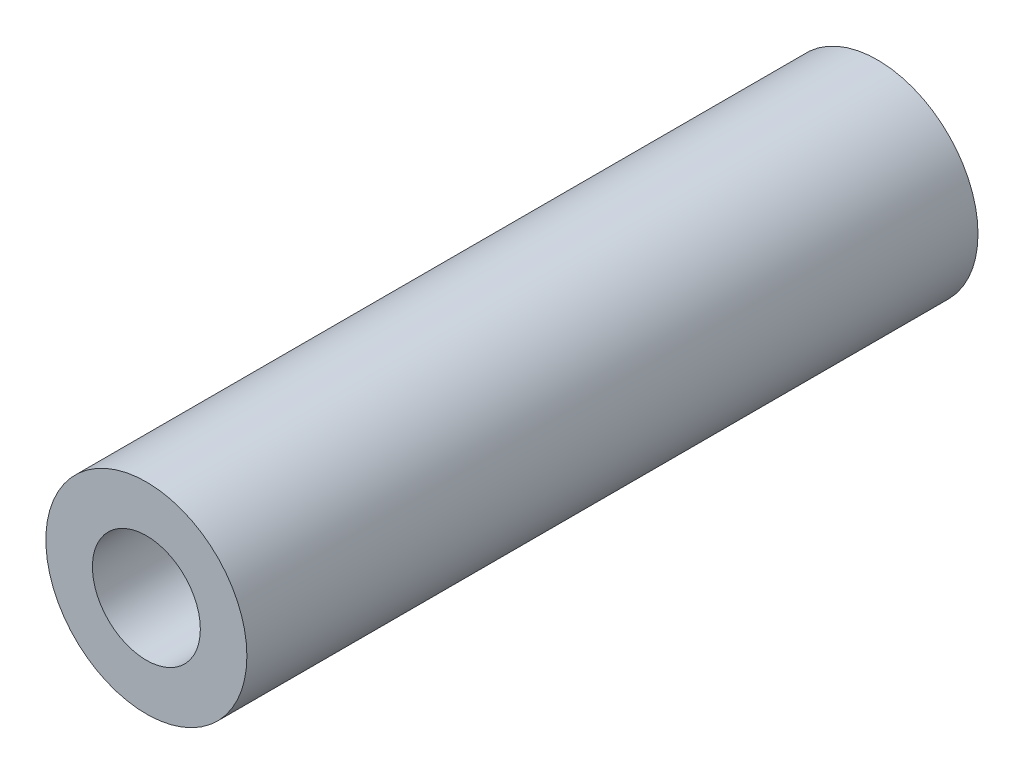
from build123d import *

# Parameters (mm, degrees)
SKETCH1_R           = 2.794
SKETCH1_R_2         = 1.5
BOSS_EXTRUDE1_DEPTH = 20.32


with BuildPart() as part:
    # Sketch1 → Boss-Extrude1 (new body)
    with BuildSketch(Plane.XY):
        Circle(SKETCH1_R)
        Circle(SKETCH1_R_2, mode=Mode.SUBTRACT)
    extrude(amount=BOSS_EXTRUDE1_DEPTH)


solid = part.part
